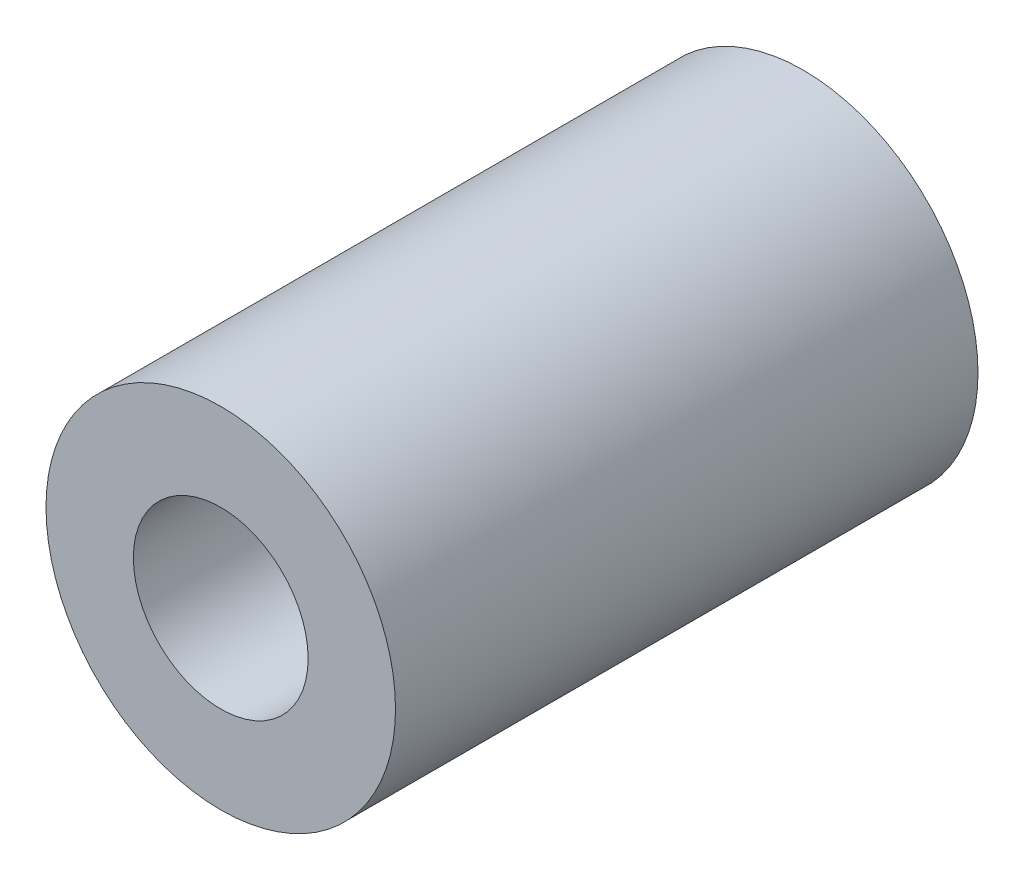
from build123d import *

# Parameters (mm, degrees)
SKETCH_1_R      = 3
SKETCH_1_R_2    = 1.5
EXTRUDE_1_DEPTH = 5


with BuildPart() as part:
    # 草图1 → 凸台-拉伸1 (new body, symmetric)
    with BuildSketch(Plane.XY):
        Circle(SKETCH_1_R)
        Circle(SKETCH_1_R_2, mode=Mode.SUBTRACT)
    extrude(amount=EXTRUDE_1_DEPTH, both=True)


solid = part.part
